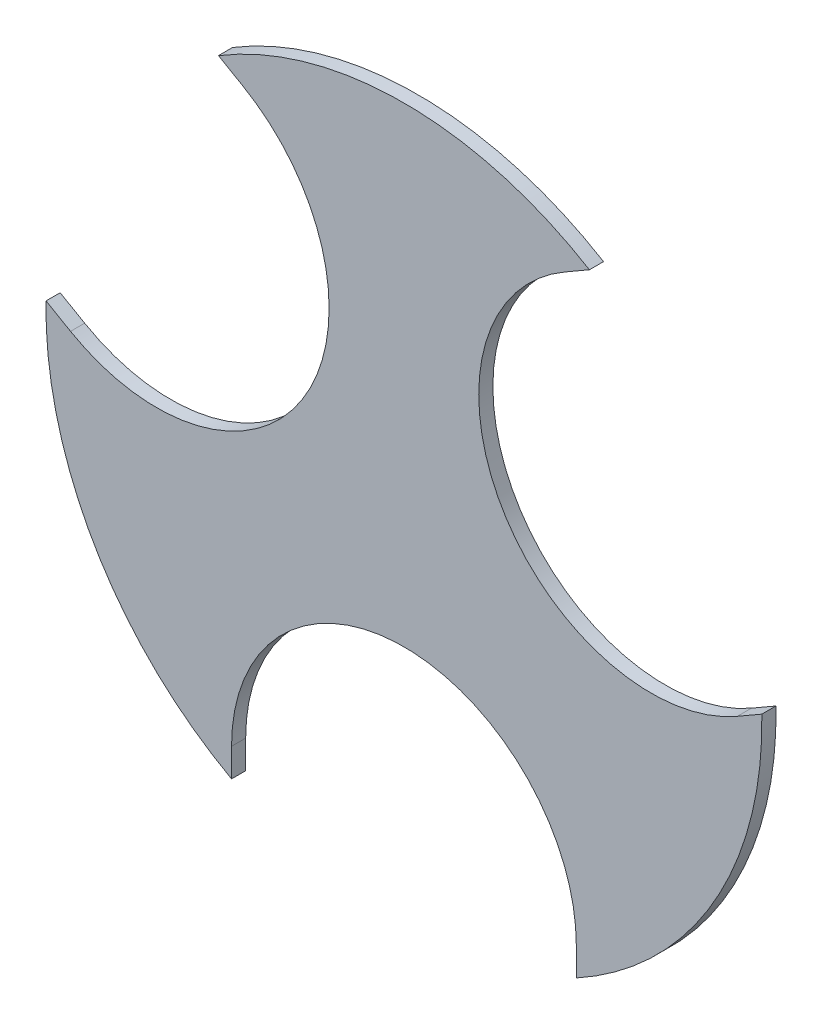
from build123d import *

# Parameters (mm, degrees)
BOSS_EXTRUDE2_DEPTH = 5


with BuildPart() as part:
    # Sketch1 → Boss-Extrude2 (new body)
    with BuildSketch(Plane.XY):
        with BuildLine():
            Line((-65.62881982, 108.327549631), (-56.968565782, 103.327549631))
            ThreePointArc((-56.968565782, 103.327549631), (-34.641016151, 20), (-117.968565782, -2.327549631))
            Line((-117.968565782, -2.327549631), (-126.62881982, 2.672450369))
            ThreePointArc((-126.62881982, 2.672450369), (-109.688194442, -63.328508588), (-61, -111))
            Line((-61, -111), (-61, -101))
            ThreePointArc((-61, -101), (0, -40), (61, -101))
            Line((61, -101), (61, -111))
            ThreePointArc((61, -111), (109.688194442, -63.328508588), (126.62881982, 2.672450369))
            Line((126.62881982, 2.672450369), (117.968565782, -2.327549631))
            ThreePointArc((117.968565782, -2.327549631), (34.641016151, 20), (56.968565782, 103.327549631))
            Line((56.968565782, 103.327549631), (65.62881982, 108.327549631))
            ThreePointArc((65.62881982, 108.327549631), (0, 126.657017176), (-65.62881982, 108.327549631))
        make_face()
    extrude(amount=BOSS_EXTRUDE2_DEPTH)


solid = part.part
